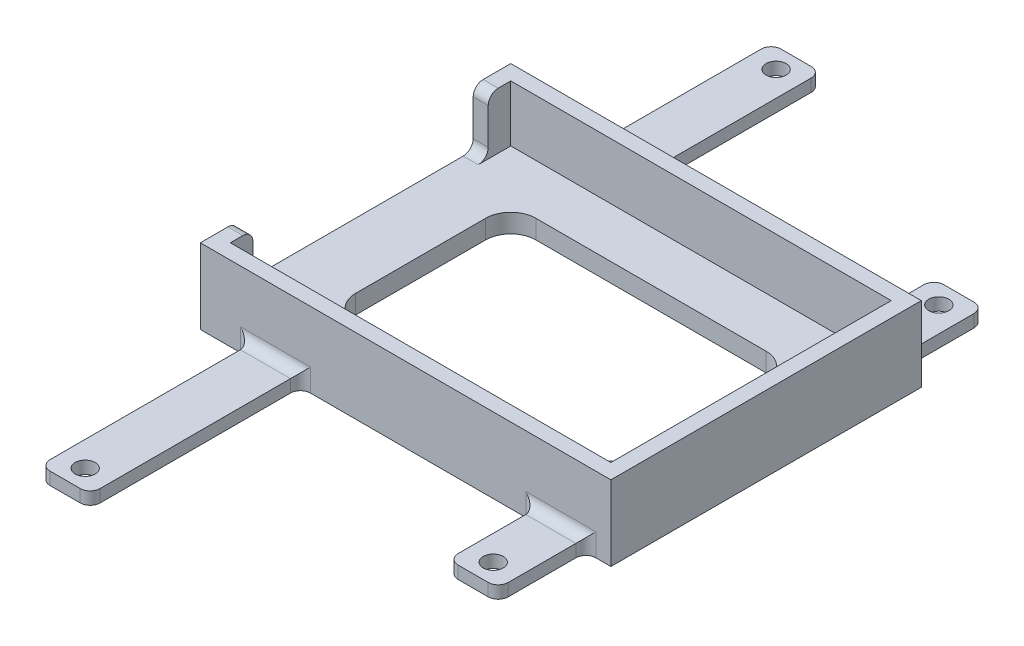
from build123d import *

# Parameters (mm, degrees)
SKETCH1_W           = 104.14
SKETCH1_H           = 78.74
BOSS_EXTRUDE1_DEPTH = 19.05
SKETCH2_W           = 96.52
SKETCH2_H           = 71.12
CUT_EXTRUDE1_DEPTH  = 14.2875
CUT_EXTRUDE2_REACH  = 6.763
SKETCH4_W           = 3.81
SKETCH4_H           = 59.69
CUT_EXTRUDE3_DEPTH  = 14.2875
FILLET1_R           = 2.54
BOSS_EXTRUDE2_DEPTH = 3.175
CUT_EXTRUDE4_REACH  = 5.175
SKETCH6_R           = 2.54
FILLET2_R           = 2.54


with BuildPart() as part:
    # Sketch1 → Boss-Extrude1 (new body)
    with BuildSketch(Plane(origin=(0, 0, 0), x_dir=(1, 0, 0), z_dir=(0, 1, 0))):
        with Locations((52.07, 39.37)):
            Rectangle(SKETCH1_W, SKETCH1_H)
    extrude(amount=BOSS_EXTRUDE1_DEPTH)

    # Sketch2 → Cut-Extrude1 (cut)
    with BuildSketch(Plane(origin=(0, 19.05, 0), x_dir=(1, 0, 0), z_dir=(0, 1, 0))):
        with Locations((52.07, 39.37)):
            Rectangle(SKETCH2_W, SKETCH2_H)
    extrude(amount=-CUT_EXTRUDE1_DEPTH, mode=Mode.SUBTRACT)

    # Sketch3 → Cut-Extrude2 (cut, up to next)
    with BuildSketch(Plane(origin=(0, 4.7625, 0), x_dir=(1, 0, 0), z_dir=(0, 1, 0)), mode=Mode.PRIVATE) as cut_extrude2_sk1:
        with BuildLine():
            Line((22.86, 62.23), (81.28, 62.23))
            ThreePointArc((81.28, 62.23), (85.770128061, 60.370128061), (87.63, 55.88))
            Line((87.63, 55.88), (87.63, 22.86))
            ThreePointArc((87.63, 22.86), (85.770128061, 18.369871939), (81.28, 16.51))
            Line((81.28, 16.51), (22.86, 16.51))
            ThreePointArc((22.86, 16.51), (18.369871939, 18.369871939), (16.51, 22.86))
            Line((16.51, 22.86), (16.51, 55.88))
            ThreePointArc((16.51, 55.88), (18.369871939, 60.370128061), (22.86, 62.23))
        make_face()
    cut_extrude2_tool1 = extrude(cut_extrude2_sk1.sketch, amount=-CUT_EXTRUDE2_REACH, mode=Mode.PRIVATE) & part.part
    add(cut_extrude2_tool1.solids().sort_by_distance((52.07, 4.7625, -39.37))[0], mode=Mode.SUBTRACT)

    # Sketch4 → Cut-Extrude3 (cut)
    with BuildSketch(Plane(origin=(0, 19.05, 0), x_dir=(1, 0, 0), z_dir=(0, 1, 0))):
        with Locations((1.905, 39.37)):
            Rectangle(SKETCH4_W, SKETCH4_H)
    extrude(amount=-CUT_EXTRUDE3_DEPTH, mode=Mode.SUBTRACT)

    # Fillet1
    fillet1_edges = [part.edges().sort_by_distance(p)[0] for p in [
        (1.905, 19.05, -69.215),
        (1.905, 19.05, -9.525),
        (1.905, 4.7625, -69.215),
        (1.905, 4.7625, -9.525),
    ]]
    fillet(fillet1_edges, radius=FILLET1_R)

    # Sketch5 → Boss-Extrude2 (add)
    with BuildSketch(Plane.XZ):
        with BuildLine():
            Line((97.79, 0), (85.09, 0))
            Line((85.09, 0), (85.09, 19.685))
            ThreePointArc((85.09, 19.685), (85.833948776, 21.481051224), (87.63, 22.225))
            Line((87.63, 22.225), (95.25, 22.225))
            ThreePointArc((95.25, 22.225), (97.046051224, 21.481051224), (97.79, 19.685))
            Line((97.79, 19.685), (97.79, 0))
        make_face()
        with BuildLine():
            Line((85.09, -78.74), (85.09, -98.425))
            ThreePointArc((85.09, -98.425), (85.833948776, -100.221051224), (87.63, -100.965))
            Line((87.63, -100.965), (95.25, -100.965))
            ThreePointArc((95.25, -100.965), (97.046051224, -100.221051224), (97.79, -98.425))
            Line((97.79, -98.425), (97.79, -78.74))
            Line((97.79, -78.74), (85.09, -78.74))
        make_face()
        with BuildLine():
            Line((12.7, 0), (25.4, 0))
            Line((25.4, 0), (25.4, 50.8))
            ThreePointArc((25.4, 50.8), (24.656051224, 52.596051224), (22.86, 53.34))
            Line((22.86, 53.34), (15.24, 53.34))
            ThreePointArc((15.24, 53.34), (13.443948776, 52.596051224), (12.7, 50.8))
            Line((12.7, 50.8), (12.7, 0))
        make_face()
        with BuildLine():
            Line((25.4, -78.74), (25.4, -129.54))
            ThreePointArc((25.4, -129.54), (24.656051224, -131.336051224), (22.86, -132.08))
            Line((22.86, -132.08), (15.24, -132.08))
            ThreePointArc((15.24, -132.08), (13.443948776, -131.336051224), (12.7, -129.54))
            Line((12.7, -129.54), (12.7, -78.74))
            Line((12.7, -78.74), (25.4, -78.74))
        make_face()
    extrude(amount=-BOSS_EXTRUDE2_DEPTH)

    # Sketch6 → Cut-Extrude4 (cut, up to next)
    with BuildSketch(Plane(origin=(0, 3.175, 0), x_dir=(1, 0, 0), z_dir=(0, 1, 0)), mode=Mode.PRIVATE) as cut_extrude4_sk1:
        with Locations((19.05, 127)):
            Circle(SKETCH6_R)
    cut_extrude4_tool1 = extrude(cut_extrude4_sk1.sketch, amount=-CUT_EXTRUDE4_REACH, mode=Mode.PRIVATE) & part.part
    add(cut_extrude4_tool1.solids().sort_by_distance((19.05, 3.175, -127))[0], mode=Mode.SUBTRACT)
    # Sketch6 → Cut-Extrude4 (cut, up to next)
    with BuildSketch(Plane(origin=(0, 3.175, 0), x_dir=(1, 0, 0), z_dir=(0, 1, 0)), mode=Mode.PRIVATE) as cut_extrude4_sk2:
        with Locations((19.05, -48.26)):
            Circle(SKETCH6_R)
    cut_extrude4_tool2 = extrude(cut_extrude4_sk2.sketch, amount=-CUT_EXTRUDE4_REACH, mode=Mode.PRIVATE) & part.part
    add(cut_extrude4_tool2.solids().sort_by_distance((19.05, 3.175, 48.26))[0], mode=Mode.SUBTRACT)
    # Sketch6 → Cut-Extrude4 (cut, up to next)
    with BuildSketch(Plane(origin=(0, 3.175, 0), x_dir=(1, 0, 0), z_dir=(0, 1, 0)), mode=Mode.PRIVATE) as cut_extrude4_sk3:
        with Locations((91.44, -17.145)):
            Circle(SKETCH6_R)
    cut_extrude4_tool3 = extrude(cut_extrude4_sk3.sketch, amount=-CUT_EXTRUDE4_REACH, mode=Mode.PRIVATE) & part.part
    add(cut_extrude4_tool3.solids().sort_by_distance((91.44, 3.175, 17.145))[0], mode=Mode.SUBTRACT)
    # Sketch6 → Cut-Extrude4 (cut, up to next)
    with BuildSketch(Plane(origin=(0, 3.175, 0), x_dir=(1, 0, 0), z_dir=(0, 1, 0)), mode=Mode.PRIVATE) as cut_extrude4_sk4:
        with Locations((91.44, 95.885)):
            Circle(SKETCH6_R)
    cut_extrude4_tool4 = extrude(cut_extrude4_sk4.sketch, amount=-CUT_EXTRUDE4_REACH, mode=Mode.PRIVATE) & part.part
    add(cut_extrude4_tool4.solids().sort_by_distance((91.44, 3.175, -95.885))[0], mode=Mode.SUBTRACT)

    # Fillet2
    fillet2_edges = [part.edges().sort_by_distance(p)[0] for p in [
        (91.44, 3.175, 0),
        (97.79, 1.5875, 0),
        (85.09, 1.5875, 0),
        (91.44, 3.175, -78.74),
        (85.09, 1.5875, -78.74),
        (97.79, 1.5875, -78.74),
        (12.7, 1.5875, 0),
        (19.05, 3.175, 0),
        (25.4, 1.5875, 0),
        (19.05, 3.175, -78.74),
        (12.7, 1.5875, -78.74),
        (25.4, 1.5875, -78.74),
    ]]
    fillet(fillet2_edges, radius=FILLET2_R)


solid = part.part
